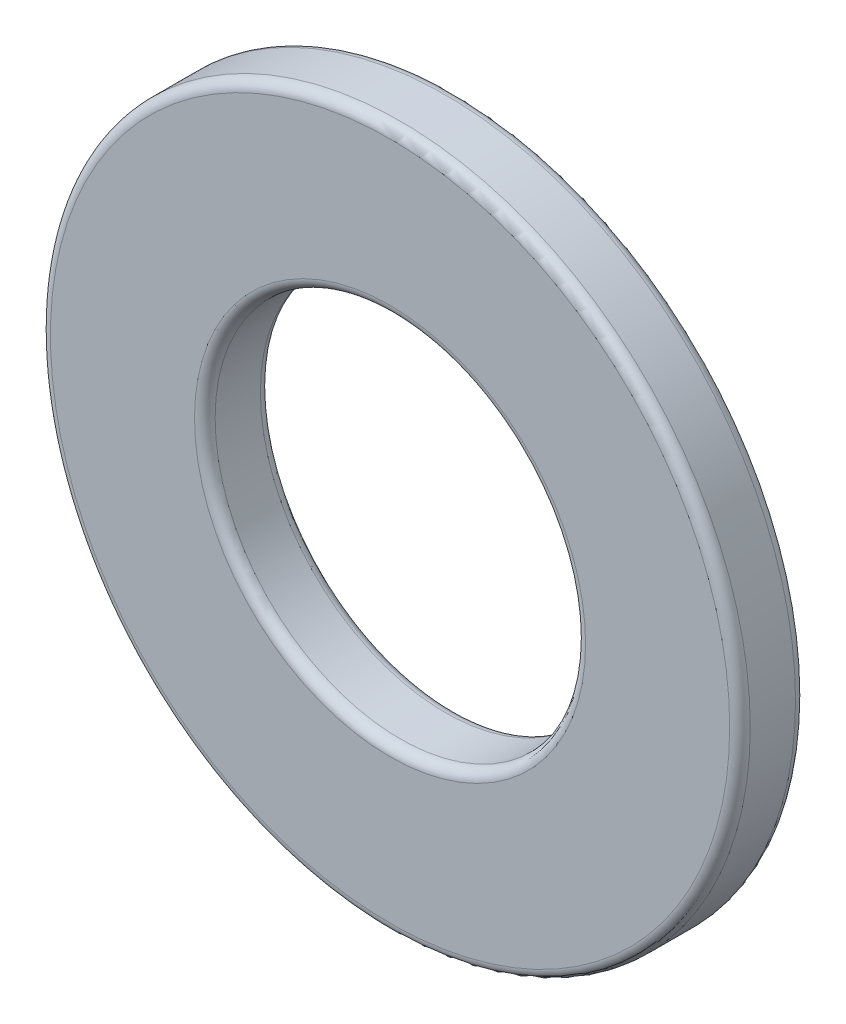
from build123d import *

# Parameters (mm, degrees)
SKETCH1_R           = 8.5
SKETCH1_R_2         = 4.5
BOSS_EXTRUDE1_DEPTH = 1.6
FILLET1_R           = 0.25


with BuildPart() as part:
    # Sketch1 → Boss-Extrude1 (new body)
    with BuildSketch(Plane.XY):
        Circle(SKETCH1_R)
        Circle(SKETCH1_R_2, mode=Mode.SUBTRACT)
    extrude(amount=BOSS_EXTRUDE1_DEPTH)

    # Fillet1
    fillet1_edges = [part.edges().sort_by_distance(p)[0] for p in [
        (-8.5, 0, 0),
        (-8.5, 0, 1.6),
        (-4.5, 0, 0),
        (-4.5, 0, 1.6),
    ]]
    fillet(fillet1_edges, radius=FILLET1_R)


solid = part.part
